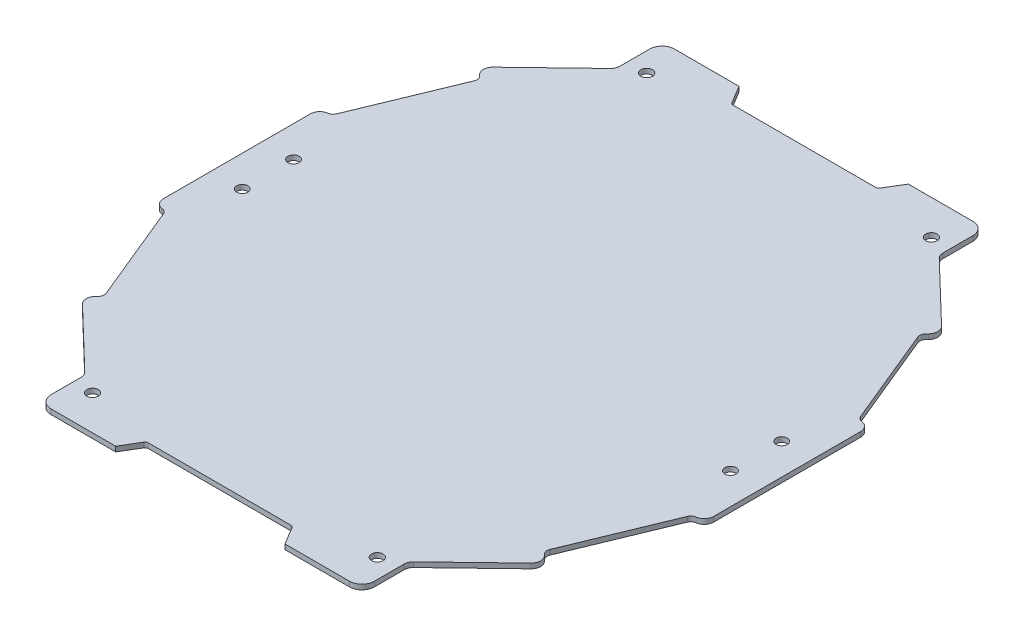
from build123d import *

# Parameters (mm, degrees)
SKETCH1_R        = 1.8
SKETCH1_R_2      = 1.85915493
EXTRUSION1_DEPTH = 1.6
FILLET1_R        = 1
FILLET2_R        = 4
FILLET3_R        = 3
FILLET4_R        = 3
FILLET5_R        = 2
FILLET6_R        = 2
FILLET7_R        = 3
FILLET8_R        = 3
FILLET9_R        = 2
FILLET10_R       = 2
FILLET11_R       = 3


with BuildPart() as part:
    # Sketch1 → Extrusion1 (new body)
    with BuildSketch(Plane(origin=(0, 0, 0), x_dir=(-1, 0, 0), z_dir=(0, 1, 0))):
        Polygon((74.087520418, 321.088295015), (70.369210559, 327.285477572), (45.580478165, 327.285477572), (45.580478165, 312.412238135), (23.246043749, 290.934342561), (26.682507041, 287.360833055), (12.735407819, 253.538985229), (9.017097883, 253.538985229), (9.017097883, 226.891111382), (9.017097883, 200.243237534), (12.735407819, 200.243237534), (26.682507041, 166.421389708), (23.246043749, 162.847880202), (45.580478165, 141.369984628), (45.580478165, 126.496745191), (70.369210559, 126.496745191), (74.087520418, 132.693927748), (97.636816193, 132.693927748), (121.186111968, 132.693927748), (124.904421827, 126.496745191), (149.693154221, 126.496745191), (149.693154221, 141.369984628), (172.027588636, 162.847880202), (168.591125345, 166.421389708), (182.538224567, 200.243237534), (186.256534503, 200.243237534), (186.256534503, 226.891111382), (186.256534503, 253.538985229), (182.538224567, 253.538985229), (168.591125345, 287.360833055), (172.027588636, 290.934342561), (149.693154221, 312.412238135), (149.693154221, 327.285477572), (124.904421827, 327.285477572), (121.186111968, 321.088295015), (97.636816193, 321.088295015), align=None)
        with Locations((176.256534503, 218.641111382)):
            Circle(SKETCH1_R, mode=Mode.SUBTRACT)
        with Locations((176.256534503, 235.141111382)):
            Circle(SKETCH1_R, mode=Mode.SUBTRACT)
        with Locations((19.017097883, 218.641111382)):
            Circle(SKETCH1_R, mode=Mode.SUBTRACT)
        with Locations((19.017097883, 235.141111382)):
            Circle(SKETCH1_R, mode=Mode.SUBTRACT)
        with Locations((51.777661187, 316.130534525)):
            Circle(SKETCH1_R_2, mode=Mode.SUBTRACT)
        with Locations((143.495971199, 137.651688238)):
            Circle(SKETCH1_R_2, mode=Mode.SUBTRACT)
        with Locations((143.495971199, 316.130534525)):
            Circle(SKETCH1_R_2, mode=Mode.SUBTRACT)
        with Locations((51.777661187, 137.651688238)):
            Circle(SKETCH1_R_2, mode=Mode.SUBTRACT)
    extrude(amount=EXTRUSION1_DEPTH)

    # Fillet1
    fillet1_edges = [part.edges().sort_by_distance(p)[0] for p in [
        (-121.186111968, 0.8, 321.088295015),
        (-121.186111968, 0.8, 132.693927748),
        (-74.087520418, 0.8, 132.693927748),
        (-74.087520418, 0.8, 321.088295015),
    ]]
    fillet(fillet1_edges, radius=FILLET1_R)

    # Fillet2
    fillet2_edges = [part.edges().sort_by_distance(p)[0] for p in [
        (-149.693154221, 0.8, 327.285477572),
        (-149.693154221, 0.8, 126.496745191),
        (-45.580478165, 0.8, 126.496745191),
        (-45.580478165, 0.8, 327.285477572),
    ]]
    fillet(fillet2_edges, radius=FILLET2_R)

    # Fillet3
    fillet3_edges = [part.edges().sort_by_distance(p)[0] for p in [
        (-149.693154221, 0.8, 312.412238135),
        (-149.693154221, 0.8, 141.369984628),
        (-45.580478165, 0.8, 141.369984628),
        (-45.580478165, 0.8, 312.412238135),
    ]]
    fillet(fillet3_edges, radius=FILLET3_R)

    # Fillet4
    fillet4_edges = [part.edges().sort_by_distance(p)[0] for p in [
        (-172.027588636, 0.8, 290.934342561),
    ]]
    fillet(fillet4_edges, radius=FILLET4_R)

    # Fillet5
    fillet5_edges = [part.edges().sort_by_distance(p)[0] for p in [
        (-168.591125345, 0.8, 287.360833055),
    ]]
    fillet(fillet5_edges, radius=FILLET5_R)

    # Fillet6
    fillet6_edges = [part.edges().sort_by_distance(p)[0] for p in [
        (-26.682507041, 0.8, 287.360833055),
    ]]
    fillet(fillet6_edges, radius=FILLET6_R)

    # Fillet7
    fillet7_edges = [part.edges().sort_by_distance(p)[0] for p in [
        (-23.246043749, 0.8, 290.934342561),
    ]]
    fillet(fillet7_edges, radius=FILLET7_R)

    # Fillet8
    fillet8_edges = [part.edges().sort_by_distance(p)[0] for p in [
        (-172.027588636, 0.8, 162.847880202),
        (-23.246043749, 0.8, 162.847880202),
    ]]
    fillet(fillet8_edges, radius=FILLET8_R)

    # Fillet9
    fillet9_edges = [part.edges().sort_by_distance(p)[0] for p in [
        (-168.591125345, 0.8, 166.421389708),
        (-26.682507041, 0.8, 166.421389708),
    ]]
    fillet(fillet9_edges, radius=FILLET9_R)

    # Fillet10
    fillet10_edges = [part.edges().sort_by_distance(p)[0] for p in [
        (-182.538224567, 0.8, 253.538985229),
        (-182.538224567, 0.8, 200.243237534),
        (-12.735407819, 0.8, 200.243237534),
        (-12.735407819, 0.8, 253.538985229),
    ]]
    fillet(fillet10_edges, radius=FILLET10_R)

    # Fillet11
    fillet11_edges = [part.edges().sort_by_distance(p)[0] for p in [
        (-186.256534503, 0.8, 200.243237534),
        (-186.256534503, 0.8, 253.538985229),
        (-9.017097883, 0.8, 253.538985229),
        (-9.017097883, 0.8, 200.243237534),
    ]]
    fillet(fillet11_edges, radius=FILLET11_R)


solid = part.part
